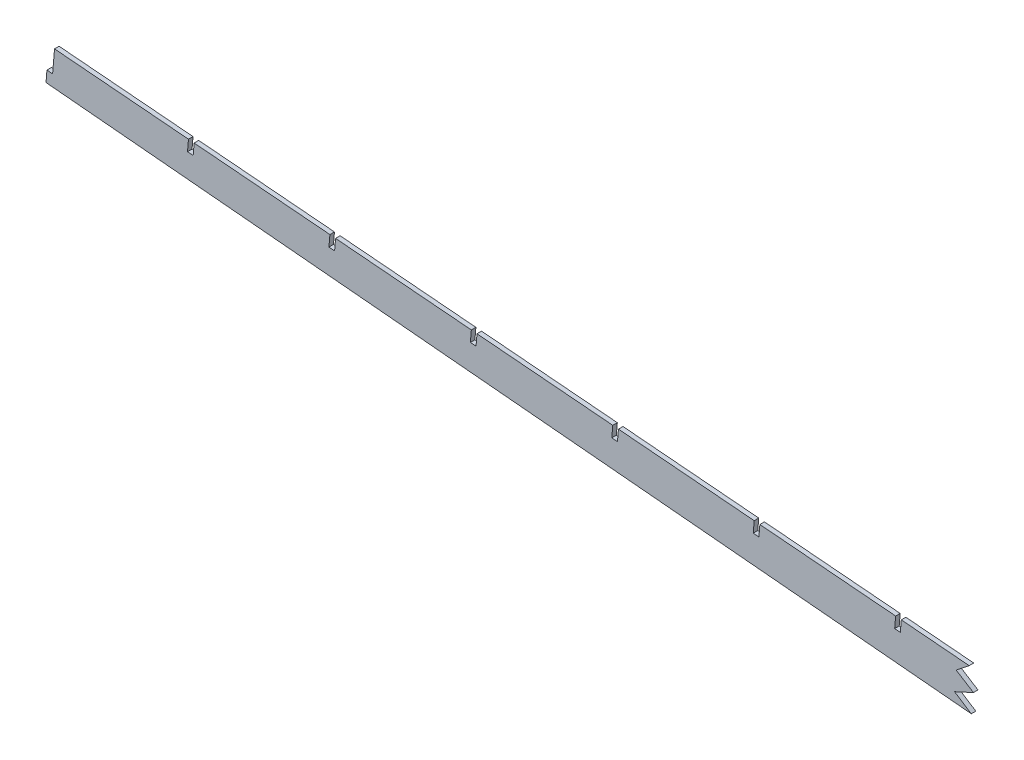
from build123d import *

# Parameters (mm, degrees)
BOSS_EXTRUDE1_DEPTH     = 2.54
CUT_EXTRUDE1_DEPTH      = 1
CUT_EXTRUDE1_DEPTH_BACK = 3.54
CUT_EXTRUDE2_DEPTH      = 7.62


with BuildPart() as part:
    # Sketch1 → Boss-Extrude1 (new body)
    with BuildSketch(Plane.XY):
        Polygon((-945.957227657, 86.137779906), (-945.969713578, 86.1172966), (-949.121092485, 86.403457059), (-949.65244679, 80.075727402), (-9.887238192, -5.25964904), (-6.723373364, -5.525326193), (0, -5.833733414), (152.4, -5.833733414), (152.4, 11.946266586), (139.7, 11.946266586), (139.7, 6.866266586), (136.525, 6.866266586), (136.525, 11.946266586), (95.25, 11.946266586), (95.25, 6.866266586), (92.075, 6.866266586), (92.075, 11.946266586), (79.375, 11.946266586), (79.375, 6.866266586), (76.2, 6.866266586), (76.2, 11.946266586), (69.85, 11.946266586), (25.4, 19.566266586), (19.05, 19.566266586), (19.05, 14.486266586), (15.875, 14.486266586), (15.875, 19.566266586), (3.175, 19.566266586), (3.175, 13.216266586), (0, 13.216266586), (0, 19.566266586), (-1.98607431, 19.566266586), (-4.597956143, 19.785592432), (-5.129310448, 13.457862776), (-8.293175277, 13.723539928), (-7.761820971, 20.051269584), (-944.89858306, 98.744842179), align=None)
    extrude(amount=BOSS_EXTRUDE1_DEPTH)

    # Sketch2 → Cut-Extrude1 (cut, two sides)
    with BuildSketch(Plane.XY.offset(2.54)) as cut_extrude1_sk:
        Polygon((-867.4716203, 85.879017088), (-866.940953695, 92.198557139), (-870.104818523, 92.464234292), (-870.635482595, 86.144724398), align=None)
        Polygon((-788.501617399, 79.246962625), (-787.970887585, 85.567255411), (-791.134752413, 85.832932563), (-791.665479694, 79.512669935), align=None)
        Polygon((-709.531614498, 72.614908162), (-709.000821475, 78.935953682), (-712.164686303, 79.201630835), (-712.695476794, 72.880615473), align=None)
        Polygon((-630.561611597, 65.9828537), (-630.030755365, 72.304651954), (-633.194620194, 72.570329107), (-633.725473893, 66.24856101), align=None)
        Polygon((-551.591608696, 59.350799237), (-551.060689256, 65.673350226), (-554.224554084, 65.939027378), (-554.755470992, 59.616506547), align=None)
        Polygon((-472.621605795, 52.718744774), (-472.090623146, 59.042048497), (-475.254487974, 59.30772565), (-475.785468091, 52.984452084), align=None)
        Polygon((-393.651602894, 46.086690311), (-393.120557036, 52.410746769), (-396.284421864, 52.676423921), (-396.81546519, 46.352397622), align=None)
        Polygon((-314.681599993, 39.454635849), (-314.150490926, 45.77944504), (-317.314355754, 46.045122193), (-317.845462289, 39.720343159), align=None)
        Polygon((-235.711597092, 32.822581386), (-235.180424816, 39.148143312), (-238.344289645, 39.413820465), (-238.875459388, 33.088288696), align=None)
        Polygon((-156.741594191, 26.190526923), (-156.210358707, 32.516841584), (-159.374223535, 32.782518736), (-159.905456487, 26.456234233), align=None)
        Polygon((-77.240292597, 25.885539855), (-80.404157425, 26.151217008), (-80.935453586, 19.824179771), (-77.77159129, 19.55847246), align=None)
    extrude(amount=CUT_EXTRUDE1_DEPTH, mode=Mode.SUBTRACT)
    extrude(cut_extrude1_sk.sketch, amount=-CUT_EXTRUDE1_DEPTH_BACK, mode=Mode.SUBTRACT)

    # Sketch3 → Cut-Extrude2 (cut)
    with BuildSketch(Plane.XY.offset(2.54)):
        Polygon((-434.187522505, 55.859236209), (-441.444486836, 50.074133547), (-431.803024179, 44.022577198), (-442.349656028, 39.171455119), (-433.014300591, 33.162402364), (148.326621663, -67.648294025), (201.247452175, 33.162402364), align=None)
    extrude(amount=-CUT_EXTRUDE2_DEPTH, mode=Mode.SUBTRACT)


solid = part.part
